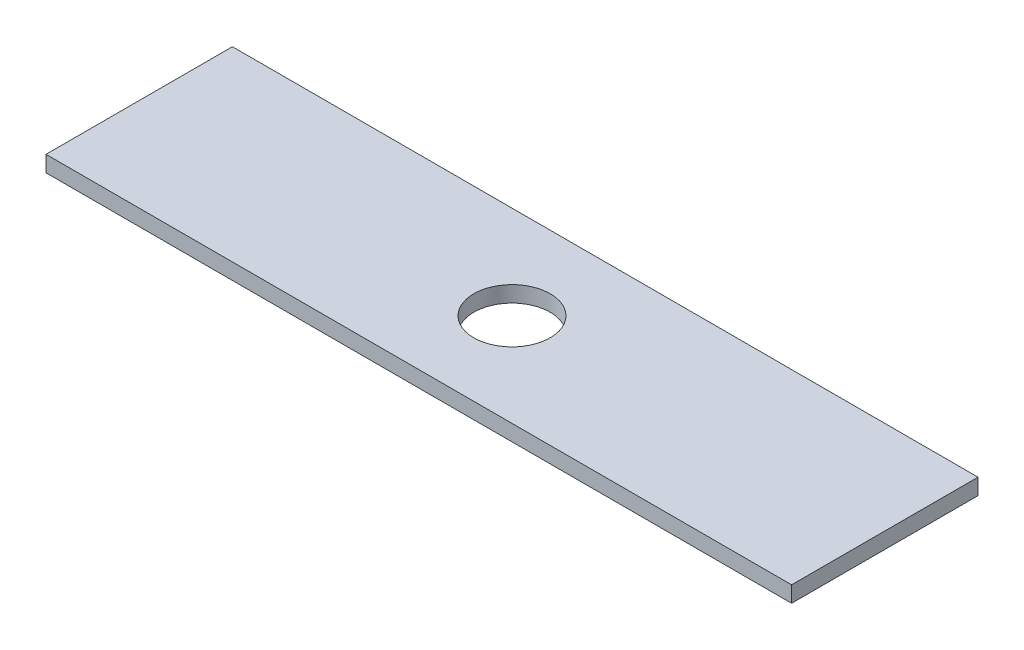
from build123d import *

# Parameters (mm, degrees)
BOSS_EXTRUDE1_DEPTH      = 1.075
BOSS_EXTRUDE1_DEPTH_BACK = 1.075
SKETCH1_W                = 100
SKETCH1_H                = 25
CUT_EXTRUDE1_DEPTH       = 52.55003031
CUT_EXTRUDE1_DEPTH_BACK  = 52.55003031
SKETCH2_R                = 5.12


with BuildPart() as part:
    # Sketch1 → Boss-Extrude1 (new, two sides: drawn at the far end of the back side and taken through both)
    with BuildSketch(Plane(origin=(0, 0, 0), x_dir=(1, 0, 0), z_dir=(0, 1, 0)).offset(-BOSS_EXTRUDE1_DEPTH_BACK)):
        Rectangle(SKETCH1_W, SKETCH1_H)
    extrude(amount=BOSS_EXTRUDE1_DEPTH + BOSS_EXTRUDE1_DEPTH_BACK)

    # Sketch2 → Cut-Extrude1 (cut, two sides: drawn at the far end of the back side and taken through both)
    with BuildSketch(Plane(origin=(0, 0, 0), x_dir=(1, 0, 0), z_dir=(0, 1, 0)).offset(-CUT_EXTRUDE1_DEPTH_BACK)):
        Circle(SKETCH2_R)
    extrude(amount=CUT_EXTRUDE1_DEPTH + CUT_EXTRUDE1_DEPTH_BACK, mode=Mode.SUBTRACT)


solid = part.part
